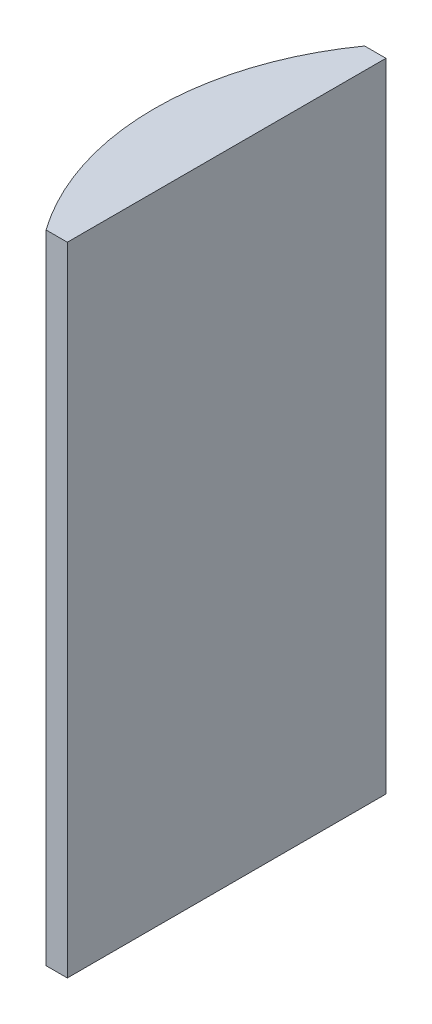
from build123d import *

# Parameters (mm, degrees)
EXTRUDE_1_DEPTH = 60


with BuildPart() as part:
    # 草图1 → 凸台-拉伸1 (new body)
    with BuildSketch(Plane(origin=(0, 0, 0), x_dir=(1, 0, 0), z_dir=(0, 1, 0))):
        with BuildLine():
            Line((-16.697645828, 15), (-14.694795665, 15))
            Line((-14.694795665, 15), (-14.694795665, -15))
            Line((-14.694795665, -15), (-16.697645828, -15))
            ThreePointArc((-16.697645828, -15), (-21.494795665, 0), (-16.697645828, 15))
        make_face()
    extrude(amount=EXTRUDE_1_DEPTH)


solid = part.part
